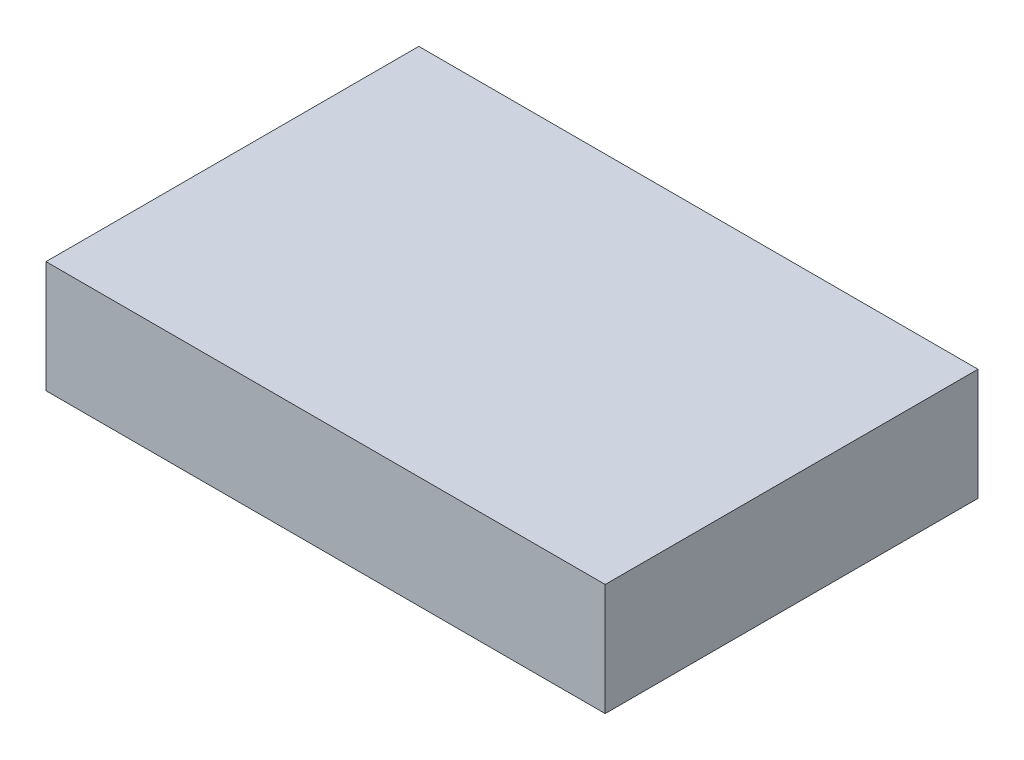
from build123d import *

# Parameters (mm, degrees)
SKETCH1_W      = 150
SKETCH1_H      = 100
EXTRUDE1_DEPTH = 30


with BuildPart() as part:
    # Sketch1 → Extrude1 (new body)
    with BuildSketch(Plane(origin=(0, 0, 0), x_dir=(1, 0, 0), z_dir=(0, 1, 0))):
        Rectangle(SKETCH1_W, SKETCH1_H)
    extrude(amount=EXTRUDE1_DEPTH)


solid = part.part
